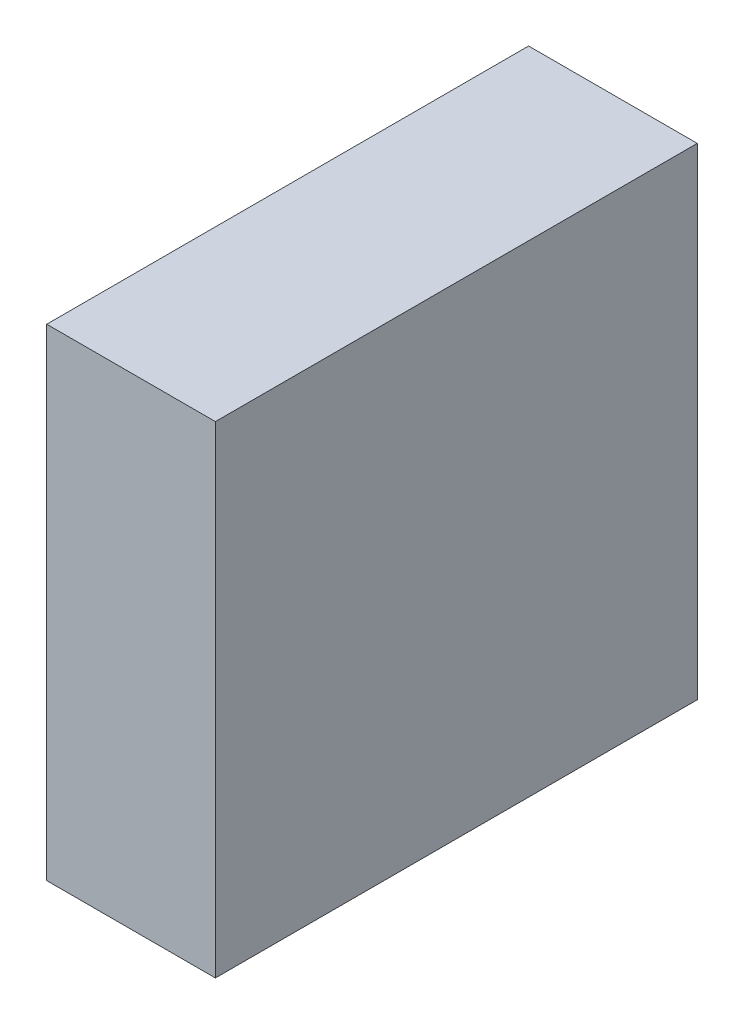
from build123d import *

# Parameters (mm, degrees)
SKETCH1_W           = 40
SKETCH1_H           = 40
BOSS_EXTRUDE1_DEPTH = 14


with BuildPart() as part:
    # Sketch1 → Boss-Extrude1 (new body)
    with BuildSketch(Plane.YZ):
        Rectangle(SKETCH1_W, SKETCH1_H)
    extrude(amount=BOSS_EXTRUDE1_DEPTH)


solid = part.part
